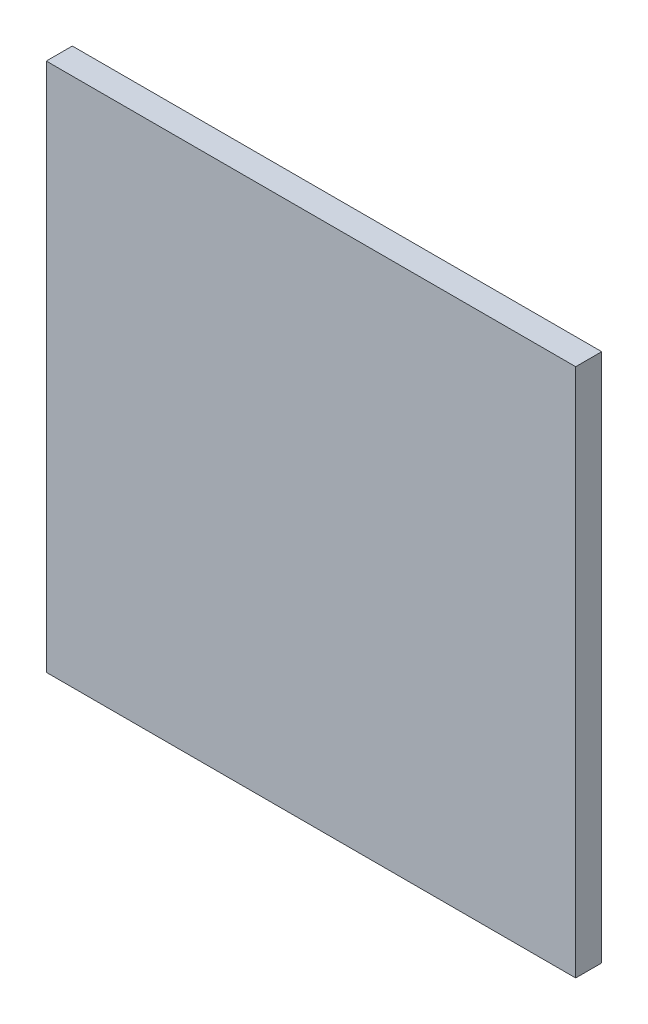
from build123d import *

# Parameters (mm, degrees)
SKETCH1_W           = 305
SKETCH1_H           = 305
BOSS_EXTRUDE1_DEPTH = 15


with BuildPart() as part:
    # Sketch1 → Boss-Extrude1 (new body)
    with BuildSketch(Plane.XY):
        Rectangle(SKETCH1_W, SKETCH1_H)
    extrude(amount=BOSS_EXTRUDE1_DEPTH)


solid = part.part
